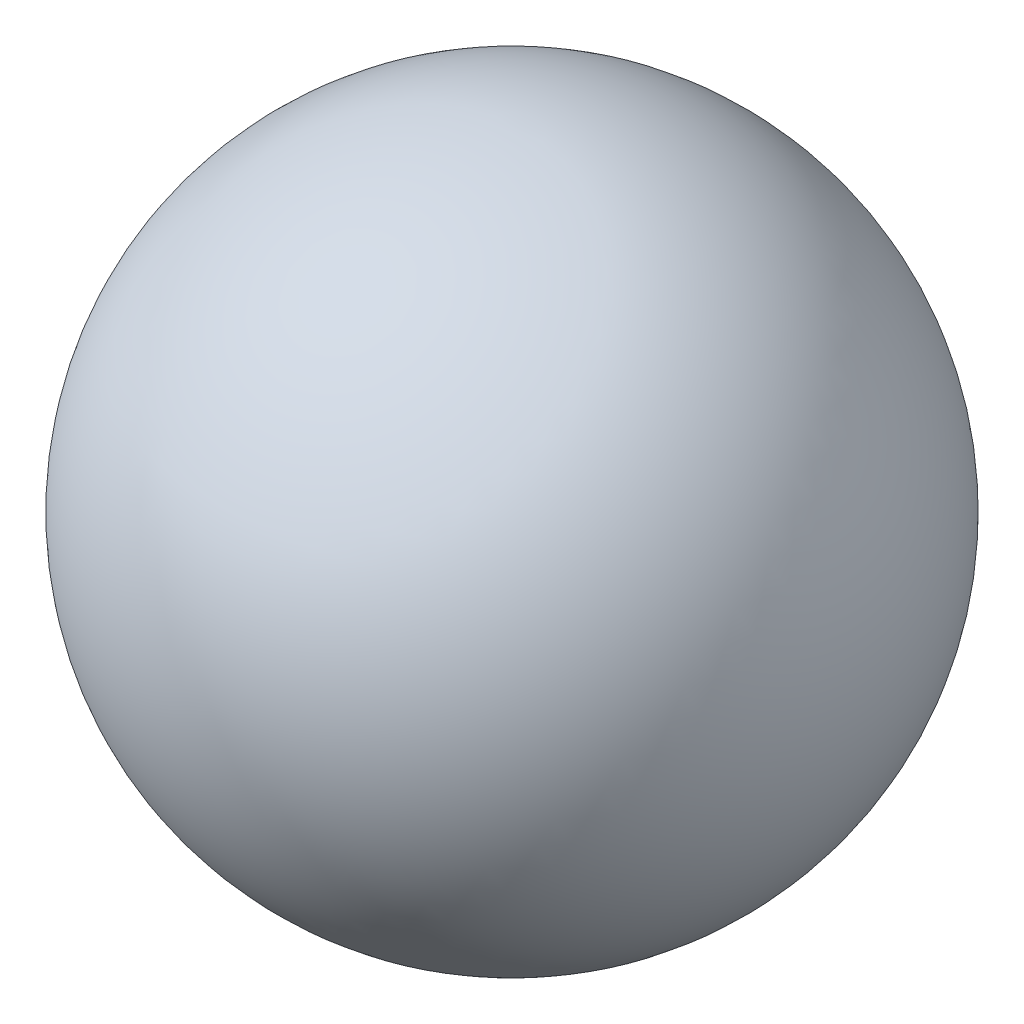
from build123d import *


with BuildPart() as part:
    # Szkic1 → Obrót4 (revolve)
    with BuildSketch(Plane.XY):
        with BuildLine():
            Line((0, 0), (0, 100))
            ThreePointArc((0, 100), (50, 50), (0, 0))
        make_face()
    revolve(axis=Axis((0, 0, 0), (0, 1, 0)))


solid = part.part
